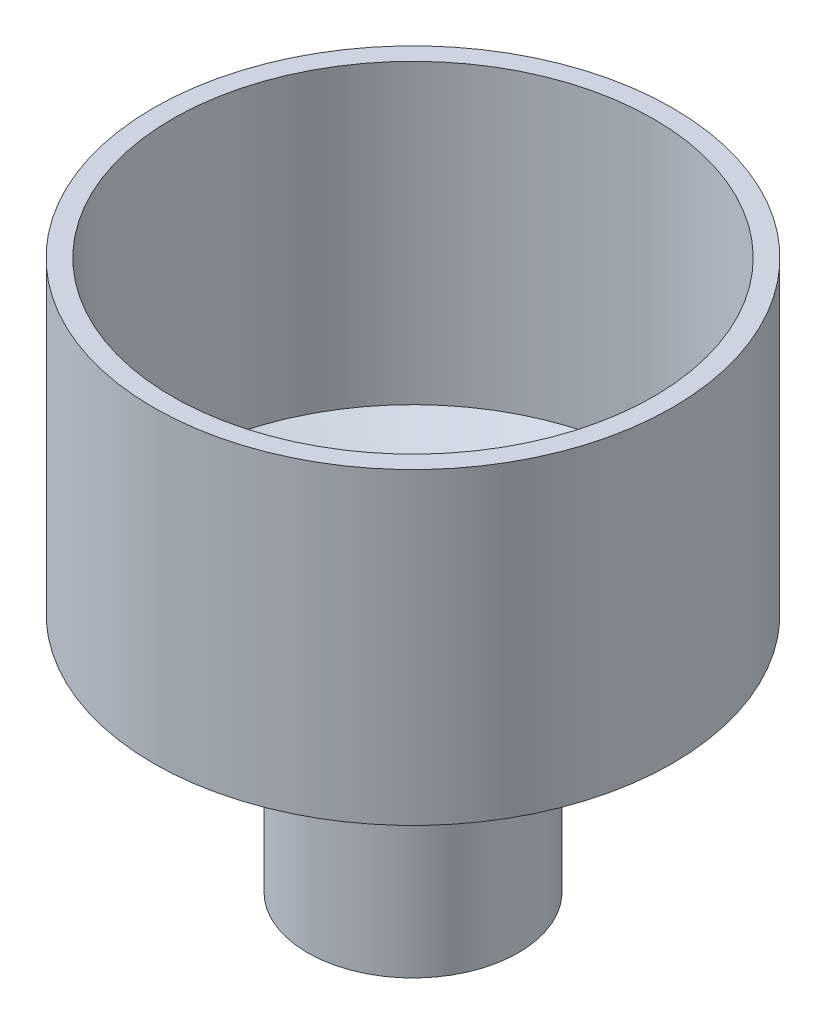
from build123d import *


with BuildPart() as part:
    # Sketch2 → Revolve1 (revolve)
    with BuildSketch(Plane.XY):
        Polygon((16, 30), (16, 0), (19.5, 0), (19.5, 27.988179765), (48, 44.588179765), (48, 101.6), (44.5, 101.6), (44.5, 46.6), align=None)
    revolve(axis=Axis((0, 0, 0), (0, 1, 0)))


solid = part.part
